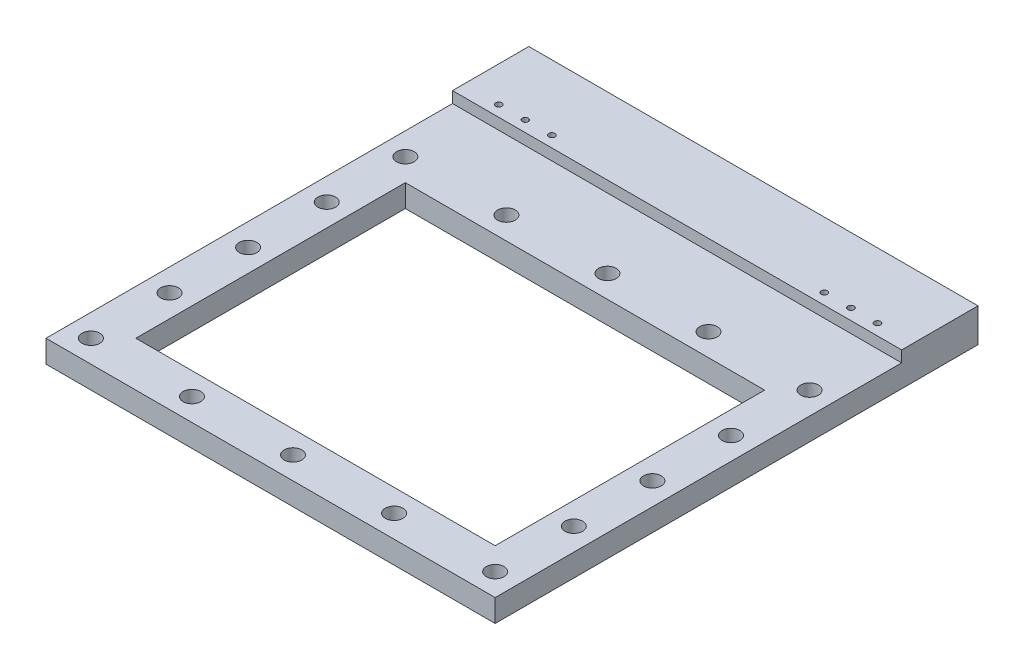
from build123d import *

# Parameters (mm, degrees)
SKETCH1_W                      = 254
SKETCH1_H                      = 203.2
SKETCH1_R                      = 3.05
SKETCH1_W_2                    = 203.2
SKETCH1_H_2                    = 152.4
BOSS_EXTRUDE1_DEPTH            = 12.7
SKETCH5_W                      = 254
SKETCH5_H                      = 19.05
BOSS_EXTRUDE3_DEPTH            = 12.7
SKETCH6_R                      = 2
CUT_EXTRUDE2_DEPTH             = 4.5
SKETCH7_R                      = 1.75
CUT_EXTRUDE3_DEPTH             = 4.5
SKETCH8_R                      = 1.75
SKETCH8_W                      = 14.64249385
SKETCH8_H                      = 9.353844035
SKETCH8_W_2                    = 16.268144154
SKETCH8_W_3                    = 13.224120591
SKETCH8_H_2                    = 10.411082314
BOSS_EXTRUDE4_DEPTH            = 12.7
SKETCH9_W                      = 254
SKETCH9_H                      = 43.18
SKETCH9_R                      = 1.75
SKETCH9_R_2                    = 1.707438486
BOSS_EXTRUDE5_DEPTH            = 6.35
CBORE_FOR_M5_SHCS2_D           = 5.8
CBORE_FOR_M5_SHCS2_CBORE_D     = 10
CBORE_FOR_M5_SHCS2_CBORE_DEPTH = 8
SKETCH12_R                     = 2
CUT_EXTRUDE4_DEPTH             = 11


with BuildPart() as part:
    # Sketch1 → Boss-Extrude1 (new body)
    with BuildSketch(Plane(origin=(0, 0, 0), x_dir=(1, 0, 0), z_dir=(0, 1, 0))):
        with Locations((127, 101.6)):
            Rectangle(SKETCH1_W, SKETCH1_H)
        with Locations((12.7, 190.5)):
            Circle(SKETCH1_R, mode=Mode.SUBTRACT)
        with Locations((241.3, 190.5)):
            Circle(SKETCH1_R, mode=Mode.SUBTRACT)
        with Locations((241.3, 12.7)):
            Circle(SKETCH1_R, mode=Mode.SUBTRACT)
        with Locations((12.7, 12.7)):
            Circle(SKETCH1_R, mode=Mode.SUBTRACT)
        with Locations((127, 101.6)):
            Rectangle(SKETCH1_W_2, SKETCH1_H_2, mode=Mode.SUBTRACT)
    extrude(amount=BOSS_EXTRUDE1_DEPTH)

    # Sketch5 → Boss-Extrude3 (add)
    with BuildSketch(Plane.XZ):
        with Locations((127, -212.725)):
            Rectangle(SKETCH5_W, SKETCH5_H)
    extrude(amount=-BOSS_EXTRUDE3_DEPTH)

    # Sketch6 → Cut-Extrude2 (cut)
    with BuildSketch(Plane(origin=(0, 12.7, 0), x_dir=(1, 0, 0), z_dir=(0, 1, 0))):
        with Locations((19.924999942, 216.120415829)):
            Circle(SKETCH6_R)
        with Locations((34.924999942, 216.120415829)):
            Circle(SKETCH6_R)
        with Locations((49.936813619, 216.120415829)):
            Circle(SKETCH6_R)
        with Locations((204.063186381, 216.120415829)):
            Circle(SKETCH6_R)
        with Locations((219.075000058, 216.120415829)):
            Circle(SKETCH6_R)
        with Locations((234.075000058, 216.120415829)):
            Circle(SKETCH6_R)
    extrude(amount=-CUT_EXTRUDE2_DEPTH, mode=Mode.SUBTRACT)

    # Sketch7 → Cut-Extrude3 (cut)
    with BuildSketch(Plane(origin=(0, 8.2, 0), x_dir=(1, 0, 0), z_dir=(0, 1, 0))):
        with Locations((19.924999942, 216.120415829)):
            Circle(SKETCH7_R)
        with Locations((34.924999942, 216.120415829)):
            Circle(SKETCH7_R)
        with Locations((49.936813619, 216.120415829)):
            Circle(SKETCH7_R)
        with Locations((204.063186381, 216.120415829)):
            Circle(SKETCH7_R)
        with Locations((219.075000058, 216.120415829)):
            Circle(SKETCH7_R)
        with Locations((234.075000058, 216.120415829)):
            Circle(SKETCH7_R)
    extrude(amount=-CUT_EXTRUDE3_DEPTH, mode=Mode.SUBTRACT)

    # Sketch8 → Boss-Extrude4 (add)
    with BuildSketch(Plane(origin=(0, 12.7, 0), x_dir=(1, 0, 0), z_dir=(0, 1, 0))):
        Polygon((0, 222.25), (13.150330977, 222.25), (13.150330977, 209.354277193), (243.652075008, 209.354277193), (243.652075008, 222.25), (254, 222.25), (254, 273.05), (0, 273.05), align=None)
        with Locations((49.936813619, 236.120415829)):
            Circle(SKETCH8_R, mode=Mode.SUBTRACT)
        with Locations((34.924999942, 236.120415829)):
            Circle(SKETCH8_R, mode=Mode.SUBTRACT)
        with Locations((19.924999942, 236.120415829)):
            Circle(SKETCH8_R, mode=Mode.SUBTRACT)
        with Locations((204.063186381, 236.120415829)):
            Circle(SKETCH8_R, mode=Mode.SUBTRACT)
        with Locations((219.075000058, 236.120415829)):
            Circle(SKETCH8_R, mode=Mode.SUBTRACT)
        with Locations((234.075000058, 236.120415829)):
            Circle(SKETCH8_R, mode=Mode.SUBTRACT)
        with Locations((12.603753017, 189.643423316)):
            Rectangle(SKETCH8_W, SKETCH8_H)
        with Locations((239.165048572, 189.643423316)):
            Rectangle(SKETCH8_W_2, SKETCH8_H)
        with Locations((240.687060353, 12.36659945)):
            Rectangle(SKETCH8_W_3, SKETCH8_H_2)
        with Locations((12.603753017, 12.36659945)):
            Rectangle(SKETCH8_W, SKETCH8_H_2)
    extrude(amount=-BOSS_EXTRUDE4_DEPTH)

    # Sketch9 → Boss-Extrude5 (add)
    with BuildSketch(Plane(origin=(0, 12.7, 0), x_dir=(1, 0, 0), z_dir=(0, 1, 0))):
        with Locations((127, 251.46)):
            Rectangle(SKETCH9_W, SKETCH9_H)
        with Locations((19.924999942, 236.120415829)):
            Circle(SKETCH9_R, mode=Mode.SUBTRACT)
        with Locations((34.924999942, 236.120415829)):
            Circle(SKETCH9_R_2, mode=Mode.SUBTRACT)
        with Locations((49.936813619, 236.120415829)):
            Circle(SKETCH9_R, mode=Mode.SUBTRACT)
        with Locations((204.063186381, 236.120415829)):
            Circle(SKETCH9_R, mode=Mode.SUBTRACT)
        with Locations((219.075000058, 236.120415829)):
            Circle(SKETCH9_R, mode=Mode.SUBTRACT)
        with Locations((234.075000058, 236.120415829)):
            Circle(SKETCH9_R, mode=Mode.SUBTRACT)
    extrude(amount=BOSS_EXTRUDE5_DEPTH)

    # CBORE for M5 SHCS2 (through all)
    with Locations(Plane(origin=(0, 12.7, 0), x_dir=(1, 0, 0), z_dir=(0, 1, 0))):
        with Locations((12.7, 101.6), (241.3, 190.5), (12.7, 12.7), (12.7, 190.5), (127, 190.5), (127, 12.7), (241.3, 12.7), (184.15, 190.5), (184.15, 12.7), (69.85, 12.7), (69.85, 190.5), (12.7, 146.05), (12.7, 57.15), (241.3, 57.15), (241.3, 146.05), (241.3, 101.6)):
            CounterBoreHole(CBORE_FOR_M5_SHCS2_D / 2, CBORE_FOR_M5_SHCS2_CBORE_D / 2, CBORE_FOR_M5_SHCS2_CBORE_DEPTH)

    # Sketch12 → Cut-Extrude4 (cut)
    with BuildSketch(Plane.XZ):
        with Locations((219.075000058, -236.120415829)):
            Circle(SKETCH12_R)
        with Locations((204.063186381, -236.120415829)):
            Circle(SKETCH12_R)
        with Locations((49.936813619, -236.120415829)):
            Circle(SKETCH12_R)
        with Locations((34.924999942, -236.120415829)):
            Circle(SKETCH12_R)
        with Locations((19.924999942, -236.120415829)):
            Circle(SKETCH12_R)
        with Locations((234.075000058, -236.120415829)):
            Circle(SKETCH12_R)
    extrude(amount=-CUT_EXTRUDE4_DEPTH, mode=Mode.SUBTRACT)


solid = part.part
